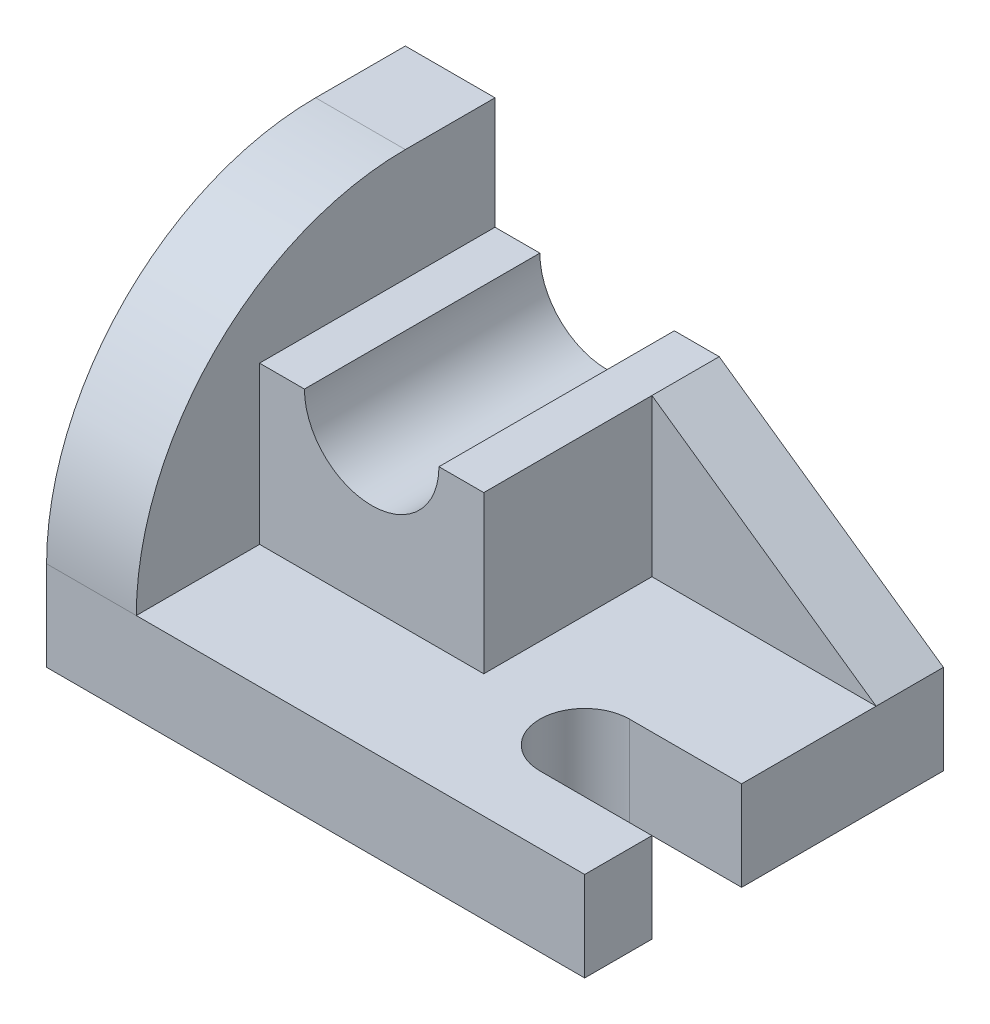
from build123d import *

# Parameters (mm, degrees)
BOSS_EXTRUDE2_DEPTH = 8
BOSS_EXTRUDE3_DEPTH = 16
BOSS_EXTRUDE4_DEPTH = 42
BOSS_EXTRUDE5_DEPTH = 12


with BuildPart() as part:
    # Sketch2 → Boss-Extrude2 (new body, symmetric)
    with BuildSketch(Plane(origin=(0, 0, 0), x_dir=(1, 0, 0), z_dir=(0, 1, 0))):
        with BuildLine():
            Line((-48, 32), (-48, -32))
            Line((-48, -32), (48, -32))
            Line((48, -32), (48, -20))
            Line((48, -20), (28, -20))
            ThreePointArc((28, -20), (20, -12), (28, -4))
            Line((28, -4), (48, -4))
            Line((48, -4), (48, 32))
            Line((48, 32), (-48, 32))
        make_face()
    extrude(amount=BOSS_EXTRUDE2_DEPTH, both=True)

    # Sketch3 → Boss-Extrude3 (add)
    with BuildSketch(Plane.ZY.offset(48)):
        with BuildLine():
            Line((-16, 8), (32, 8))
            ThreePointArc((32, 8), (17.941125497, 41.941125497), (-16, 56))
            Line((-16, 56), (-32, 56))
            Line((-32, 56), (-32, 8))
            Line((-32, 8), (-16, 8))
        make_face()
    extrude(amount=-BOSS_EXTRUDE3_DEPTH)

    # Sketch4 → Boss-Extrude4 (add)
    with BuildSketch(Plane(origin=(0, 0, -32), x_dir=(-1, 0, 0), z_dir=(0, 0, -1))):
        with BuildLine():
            ThreePointArc((24, 36), (12, 24), (0, 36))
            Line((0, 36), (-8, 36))
            Line((-8, 36), (-8, 8))
            Line((-8, 8), (32, 8))
            Line((32, 8), (32, 36))
            Line((32, 36), (24, 36))
        make_face()
    extrude(amount=-BOSS_EXTRUDE4_DEPTH)

    # Sketch5 → Boss-Extrude5 (add)
    with BuildSketch(Plane(origin=(0, 0, -32), x_dir=(-1, 0, 0), z_dir=(0, 0, -1))):
        Polygon((-8, 36), (-48, 8), (-8, 8), align=None)
    extrude(amount=-BOSS_EXTRUDE5_DEPTH)


solid = part.part
